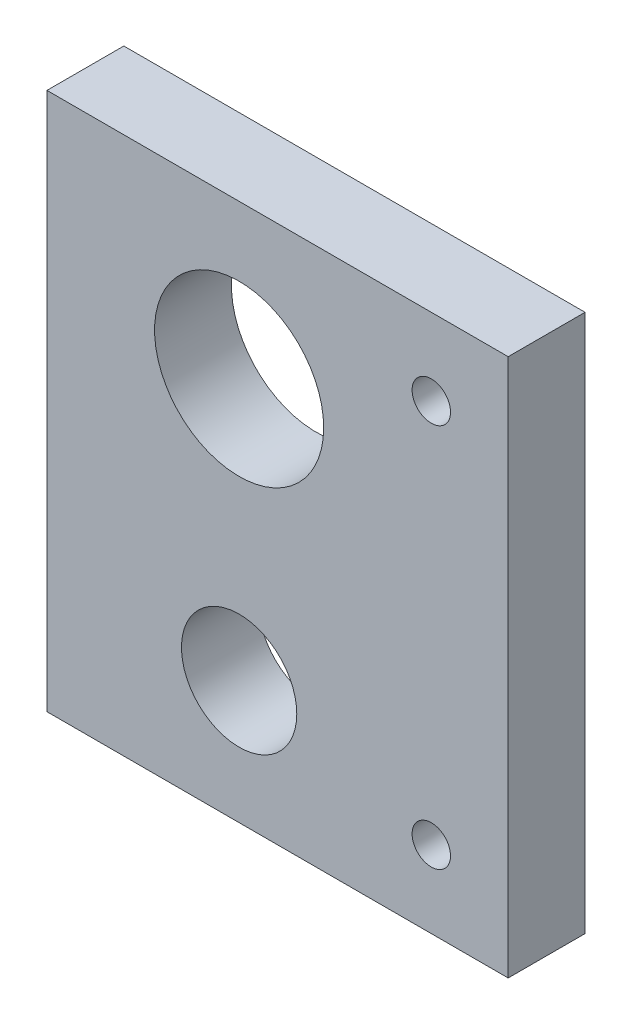
from build123d import *

# Parameters (mm, degrees)
SKETCH1_W           = 60
SKETCH1_H           = 70
SKETCH1_R           = 11
SKETCH1_R_2         = 7.5
SKETCH1_R_3         = 2.5
BOSS_EXTRUDE1_DEPTH = 10


with BuildPart() as part:
    # Sketch1 → Boss-Extrude1 (new body)
    with BuildSketch(Plane.XY):
        Rectangle(SKETCH1_W, SKETCH1_H)
        with Locations((-5, 15)):
            Circle(SKETCH1_R, mode=Mode.SUBTRACT)
        with Locations((-5, -19)):
            Circle(SKETCH1_R_2, mode=Mode.SUBTRACT)
        with Locations((20, 25)):
            Circle(SKETCH1_R_3, mode=Mode.SUBTRACT)
        with Locations((20, -25)):
            Circle(SKETCH1_R_3, mode=Mode.SUBTRACT)
    extrude(amount=BOSS_EXTRUDE1_DEPTH)


solid = part.part
